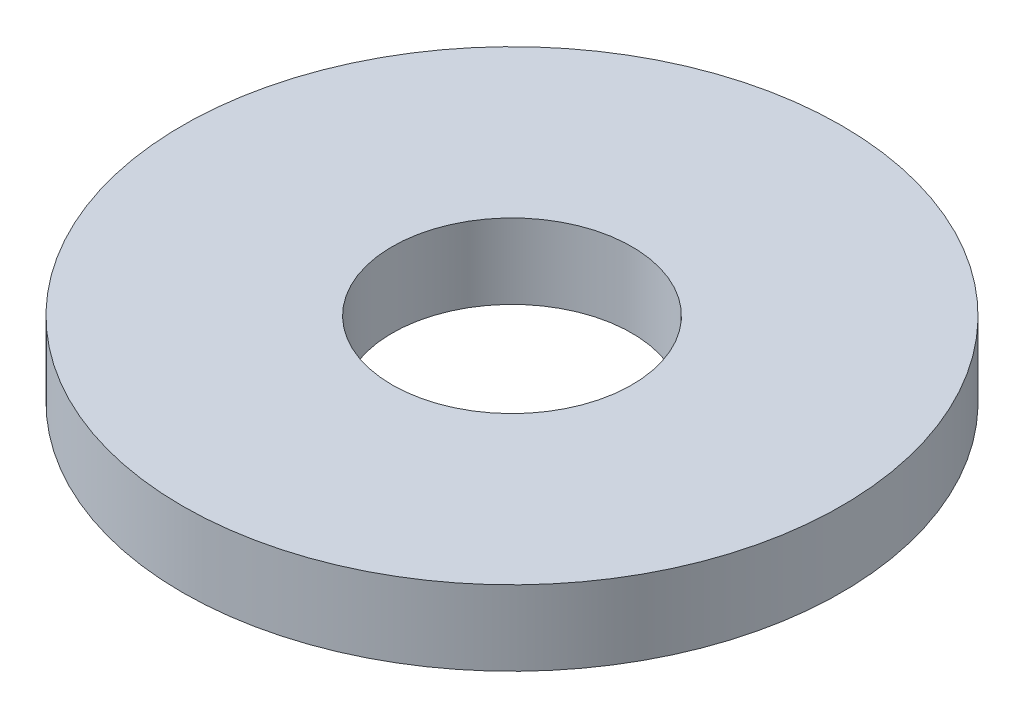
from build123d import *

# Parameters (mm, degrees)
SKETCH1_R           = 8.73125
SKETCH1_R_2         = 3.175
BOSS_EXTRUDE1_DEPTH = 1.984375


with BuildPart() as part:
    # Sketch1 → Boss-Extrude1 (new body)
    with BuildSketch(Plane(origin=(0, 0, 0), x_dir=(1, 0, 0), z_dir=(0, 1, 0))):
        Circle(SKETCH1_R)
        Circle(SKETCH1_R_2, mode=Mode.SUBTRACT)
    extrude(amount=BOSS_EXTRUDE1_DEPTH)


solid = part.part
